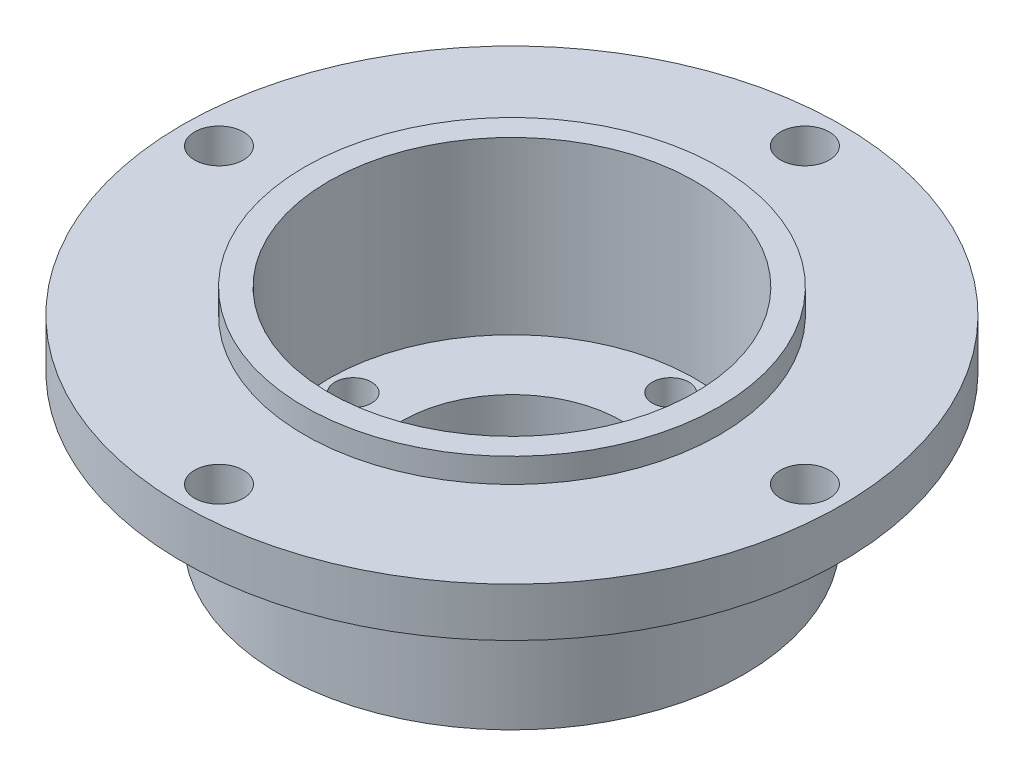
from build123d import *

# Parameters (mm, degrees)
ESQUISSE4_R      = 1.5
EXTRUSION3_DEPTH = 19
ESQUISSE3_R      = 2
EXTRUSION4_DEPTH = 7


with BuildPart() as part:
    # Esquisse1 → Révolution1 (revolve)
    with BuildSketch(Plane.XY):
        Polygon((19, -12), (27, -12), (27, -8), (17, -8), (17, -6), (15, -6), (15, -20), (9, -20), (9, -24), (19, -24), align=None)
    revolve(axis=Axis((0, 0, 0), (0, -1, 0)))

    # Esquisse4 → Extrusion3 (cut, through all)
    with BuildSketch(Plane.XZ.offset(24)):
        with Locations((0, 13)):
            Circle(ESQUISSE4_R)
        with Locations((13, 0)):
            Circle(ESQUISSE4_R)
        with Locations((0, -13)):
            Circle(ESQUISSE4_R)
        with Locations((-13, 0)):
            Circle(ESQUISSE4_R)
    extrude(amount=-EXTRUSION3_DEPTH, mode=Mode.SUBTRACT)

    # Esquisse3 → Extrusion4 (cut, through all)
    with BuildSketch(Plane.XZ.offset(12)):
        with Locations((24, 0)):
            Circle(ESQUISSE3_R)
        with Locations((0, 24)):
            Circle(ESQUISSE3_R)
        with Locations((0, -24)):
            Circle(ESQUISSE3_R)
        with Locations((-24, 0)):
            Circle(ESQUISSE3_R)
    extrude(amount=-EXTRUSION4_DEPTH, mode=Mode.SUBTRACT)


solid = part.part
